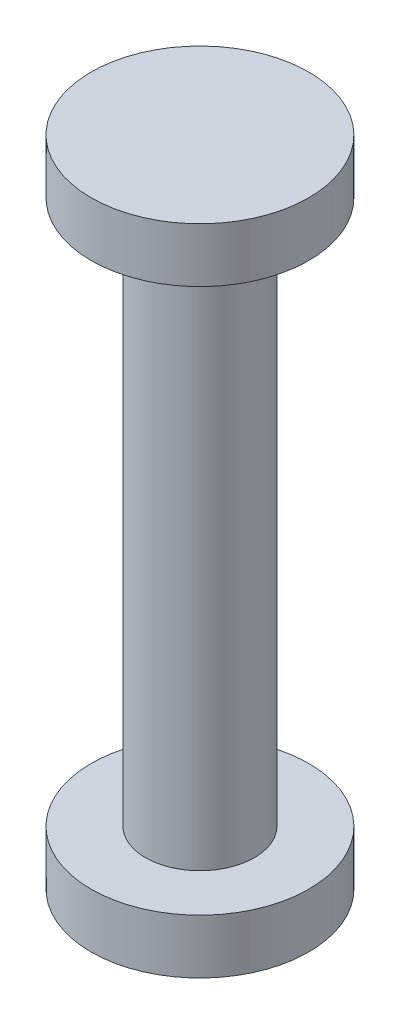
from build123d import *

# Parameters (mm, degrees)
BOSS_EXTRUDE1_START = -25
SKETCH1_R           = 5
BOSS_EXTRUDE1_DEPTH = 50
SKETCH2_R           = 10
BOSS_EXTRUDE2_DEPTH = 5


with BuildPart() as part:
    # Sketch1 → Boss-Extrude1 (new body)
    with BuildSketch(Plane(origin=(0, 0, 0), x_dir=(1, 0, 0), z_dir=(0, 1, 0)).offset(BOSS_EXTRUDE1_START)):
        Circle(SKETCH1_R)
    extrude(amount=BOSS_EXTRUDE1_DEPTH)

    # Sketch2 → Boss-Extrude2 (add)
    with BuildSketch(Plane(origin=(0, 25, 0), x_dir=(1, 0, 0), z_dir=(0, 1, 0))):
        Circle(SKETCH2_R)
    boss_extrude2 = extrude(amount=BOSS_EXTRUDE2_DEPTH)

    # Mirror1: Boss-Extrude2 across plane
    add(boss_extrude2.mirror(Plane.ZX))


solid = part.part
